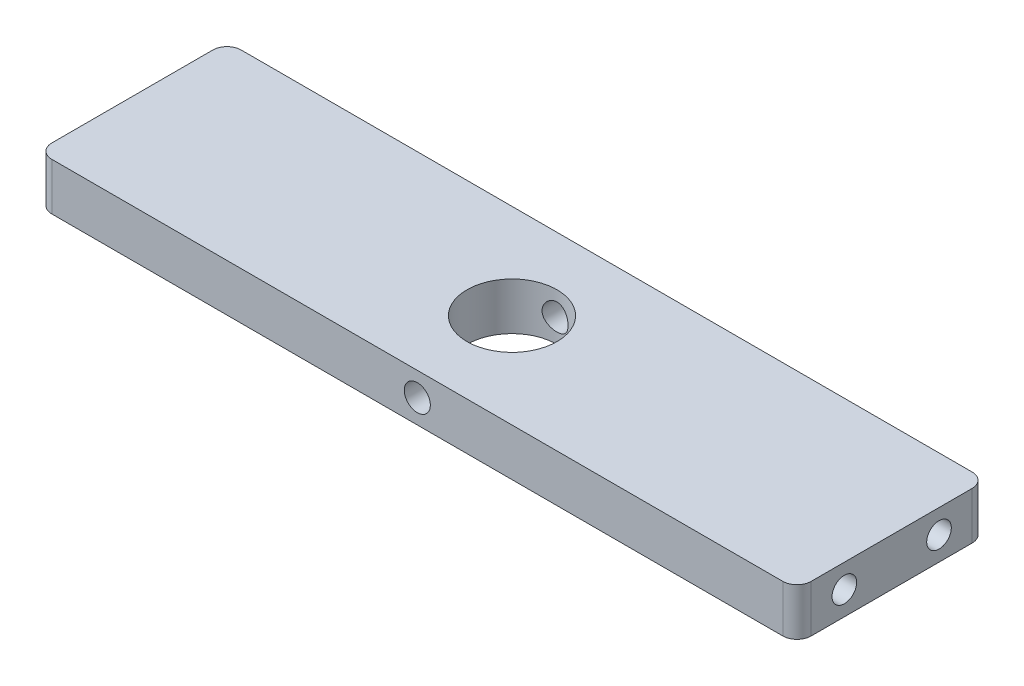
from build123d import *

# Parameters (mm, degrees)
SKETCH1_W                             = 160.4
SKETCH1_H                             = 40
SKETCH1_R                             = 9.5
BOSS_EXTRUDE1_DEPTH                   = 5
TAP_DRILL_FOR_M5_HELICOIL1_AT_2_COUNT = 2
TAP_DRILL_FOR_M5_HELICOIL1_AT_2_PITCH = 20
FILLET1_R                             = 3
M5_CLEARANCE_HOLE1_D                  = 5.5


with BuildPart() as part:
    # Sketch1 → Boss-Extrude1 (new body, symmetric)
    with BuildSketch(Plane(origin=(0, 0, 0), x_dir=(1, 0, 0), z_dir=(0, 1, 0))):
        Rectangle(SKETCH1_W, SKETCH1_H)
        Circle(SKETCH1_R, mode=Mode.SUBTRACT)
    extrude(amount=BOSS_EXTRUDE1_DEPTH, both=True)

    # Sketch4 → Tap Drill for M5 Helicoil1 (revolve, cut)
    with BuildSketch(Plane(origin=(-80.2, 0, -10), x_dir=(0, 0, 1), z_dir=(0, 1, 0))):
        Polygon((0, 0), (0, 31.562237609), (2.6, 30), (2.6, 0), align=None)
    tap_drill_for_m5_helicoil1 = revolve(axis=Axis((-86.55, 0, -10), (1, 0, 0)), mode=Mode.SUBTRACT)

    # Tap Drill for M5 Helicoil1 at 2: Tap Drill for M5 Helicoil1 ×2
    with Locations(*[(0, 0, i * TAP_DRILL_FOR_M5_HELICOIL1_AT_2_PITCH) for i in range(1, TAP_DRILL_FOR_M5_HELICOIL1_AT_2_COUNT)]):
        add(tap_drill_for_m5_helicoil1, mode=Mode.SUBTRACT)

    # Mirror1: Tap Drill for M5 Helicoil1 across plane
    add(tap_drill_for_m5_helicoil1.mirror(Plane(origin=(0, 0, 0), x_dir=(0, 0, 1), z_dir=(1, 0, 0))), mode=Mode.SUBTRACT)

    # Mirror1 copy 1 sketch → Mirror1 copy 1 (revolve, cut)
    with BuildSketch(Plane(origin=(80.2, 0, 10), x_dir=(0, 0, 1), z_dir=(0, 1, 0))):
        Polygon((0, 0), (0, -31.562237609), (2.6, -30), (2.6, 0), align=None)
    revolve(axis=Axis((86.55, 0, 10), (1, 0, 0)), mode=Mode.SUBTRACT)

    # Fillet1
    fillet1_edges = [part.edges().sort_by_distance(p)[0] for p in [
        (-80.2, 0, -20),
        (80.2, 0, -20),
        (80.2, 0, 20),
        (-80.2, 0, 20),
    ]]
    fillet(fillet1_edges, radius=FILLET1_R)

    # M5 Clearance Hole1 (through all)
    with Locations(Plane(origin=(0, 0, -20), x_dir=(-1, 0, 0), z_dir=(0, 0, -1))):
        with Locations((0, 0)):
            Hole(M5_CLEARANCE_HOLE1_D / 2)


solid = part.part
